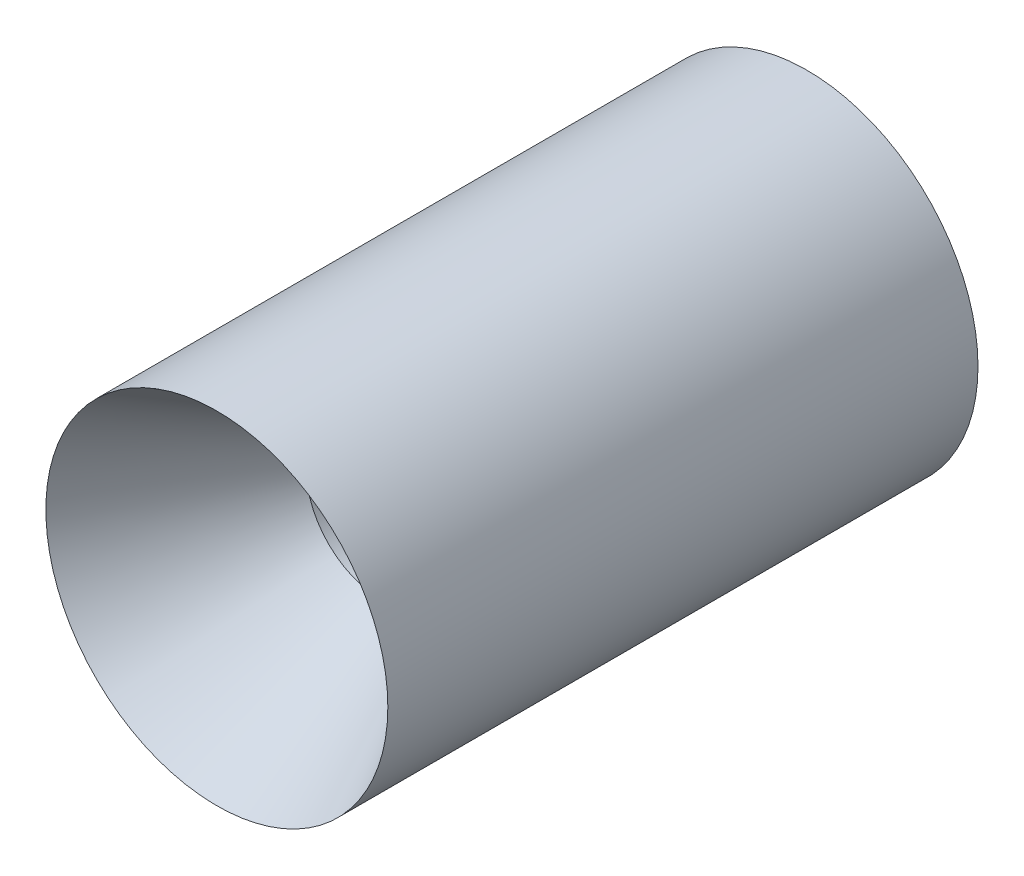
from build123d import *


with BuildPart() as part:
    # Sketch3 → Revolve1 (revolve)
    with BuildSketch(Plane(origin=(0, 0, 0), x_dir=(0, 0, -1), z_dir=(1, 0, 0))):
        Polygon((49.53, 12.720828), (49.53, 14.351), (0, 14.351), (13.858138511, 6.35), (19.557610769, 6.35), align=None)
    revolve(axis=Axis((0, 0, 0), (0, 0, -1)))


solid = part.part
